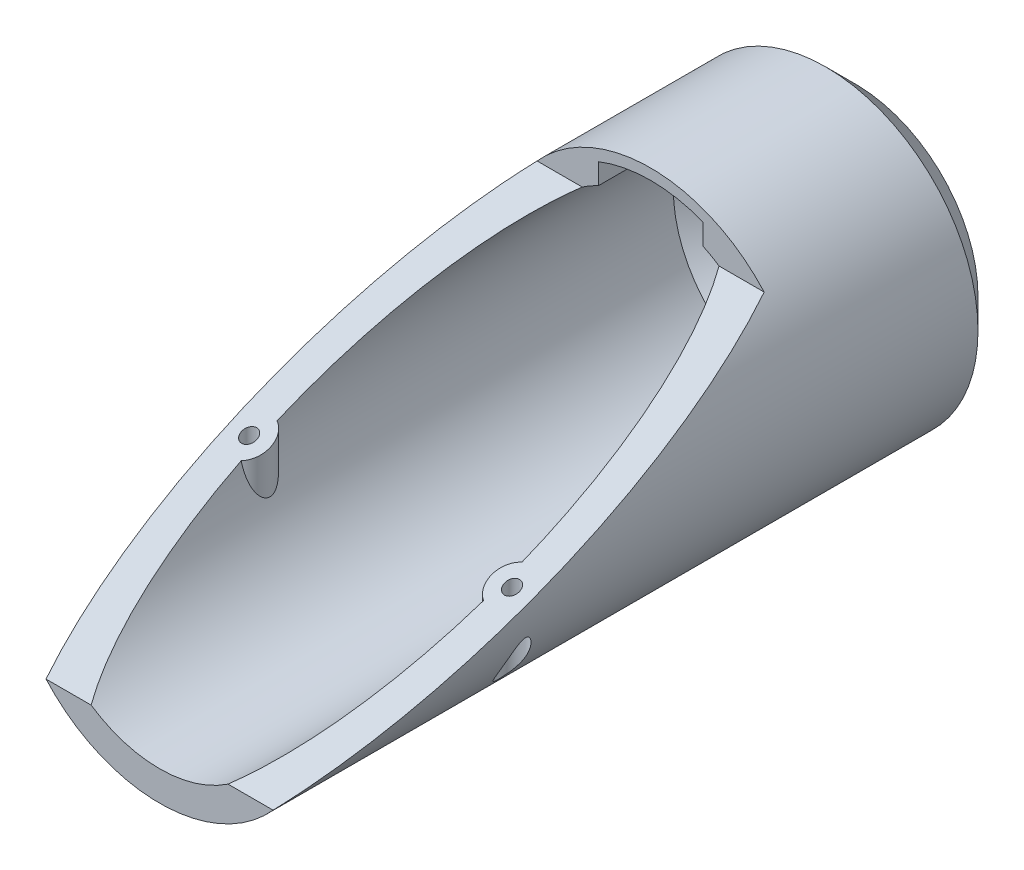
from build123d import *

# Parameters (mm, degrees)
SKETCH1_R           = 25.5
BOSS_EXTRUDE1_DEPTH = 125
SKETCH2_R           = 20.5
CUT_EXTRUDE1_DEPTH  = 120
SKETCH8_R           = 3.5
BOSS_EXTRUDE2_DEPTH = 42
SKETCH9_R           = 40.683709713
SKETCH9_R_2         = 25.5
CUT_EXTRUDE7_DEPTH  = 131.09804009
CUT_EXTRUDE2_DEPTH  = 138.390865927
SKETCH10_R          = 1.25
CUT_EXTRUDE9_DEPTH  = 130.705435597
CHAMFER2_SIZE       = 5
SKETCH11_R          = 2.25
CUT_EXTRUDE10_DEPTH = 123.852554041
CUT_EXTRUDE11_REACH = 123.954


with BuildPart() as part:
    # Sketch1 → Boss-Extrude1 (new body)
    with BuildSketch(Plane.XY):
        Circle(SKETCH1_R)
    extrude(amount=BOSS_EXTRUDE1_DEPTH)

    # Sketch2 → Cut-Extrude1 (cut)
    with BuildSketch(Plane.XY.offset(125)):
        Circle(SKETCH2_R)
    extrude(amount=-CUT_EXTRUDE1_DEPTH, mode=Mode.SUBTRACT)

    # Sketch8 → Boss-Extrude2 (add)
    with BuildSketch(Plane(origin=(0, 25.5, 0), x_dir=(1, 0, 0), z_dir=(0, 1, 0))):
        with Locations(Location((22, -79.5, 0), (0, 0, 270))):
            Circle(SKETCH8_R)
        with Locations(Location((-22, -79.5, 0), (0, 0, 180))):
            Circle(SKETCH8_R)
    extrude(amount=-BOSS_EXTRUDE2_DEPTH)

    # Sketch9 → Cut-Extrude7 (cut, through all)
    with BuildSketch(Plane.XY.offset(125)):
        Circle(SKETCH9_R)
        Circle(SKETCH9_R_2, mode=Mode.SUBTRACT)
    extrude(amount=-CUT_EXTRUDE7_DEPTH, mode=Mode.SUBTRACT)

    # Sketch3 → Cut-Extrude2 (cut, through all)
    with BuildSketch(Plane.ZY.offset(25.5)):
        Polygon((116.5, -17), (34.3, 17), (34.3, 25.5), (125, 25.5), (125, -25.5), (116.5, -25.5), align=None)
    extrude(amount=-CUT_EXTRUDE2_DEPTH, mode=Mode.SUBTRACT)

    # Sketch10 → Cut-Extrude9 (cut, through all)
    with BuildSketch(Plane(origin=(0, 25.5, 0), x_dir=(1, 0, 0), z_dir=(0, 1, 0))):
        with Locations(Location((-22, -79.5, 0), (0, 0, 270))):
            Circle(SKETCH10_R)
        with Locations(Location((22, -79.5, 0), (0, 0, 270))):
            Circle(SKETCH10_R)
    extrude(amount=-CUT_EXTRUDE9_DEPTH, mode=Mode.SUBTRACT)

    # Chamfer2
    chamfer2_edges = [part.edges().sort_by_distance(p)[0] for p in [
        (-25.5, 0, 0),
        (-20.5, 0, 5),
    ]]
    chamfer(chamfer2_edges, length=CHAMFER2_SIZE)

    # Sketch11 → Cut-Extrude10 (cut, through all)
    with BuildSketch(Plane(origin=(0, -4, 0), x_dir=(1, 0, 0), z_dir=(0, 1, 0))):
        with Locations(Location((-22, -79.5, 0), (0, 0, 270))):
            Circle(SKETCH11_R)
        with Locations(Location((22, -79.5, 0), (0, 0, 270))):
            Circle(SKETCH11_R)
    extrude(amount=-CUT_EXTRUDE10_DEPTH, mode=Mode.SUBTRACT)

    # Cut-Extrude11: up to this cone (the profile starts inside it)
    cut_extrude11_end = Plane(origin=(0, 0, 116.5), z_dir=(0, 0, 1)).offset(-126.999999) * Cone(1e-06, 378.454, 378.453999, align=(Align.CENTER, Align.CENTER, Align.MIN), mode=Mode.PRIVATE)
    # Sketch12 → Cut-Extrude11 (cut, up to the surface)
    with BuildSketch(Plane.XY.offset(116.5), mode=Mode.PRIVATE) as cut_extrude11_sk1:
        with BuildLine():
            Line((-8.75, 22.025610094), (-8.75, 18.538810641))
            ThreePointArc((-8.75, 18.538810641), (0, 20.5), (8.75, 18.538810641))
            Line((8.75, 18.538810641), (8.75, 22.025610094))
            ThreePointArc((8.75, 22.025610094), (0, 23.7), (-8.75, 22.025610094))
        make_face()
    cut_extrude11_tool1 = extrude(cut_extrude11_sk1.sketch, amount=-CUT_EXTRUDE11_REACH, mode=Mode.PRIVATE) & cut_extrude11_end
    add(cut_extrude11_tool1.solids().sort_by_distance((0, 21.490941, 116.5))[0], mode=Mode.SUBTRACT)


solid = part.part
